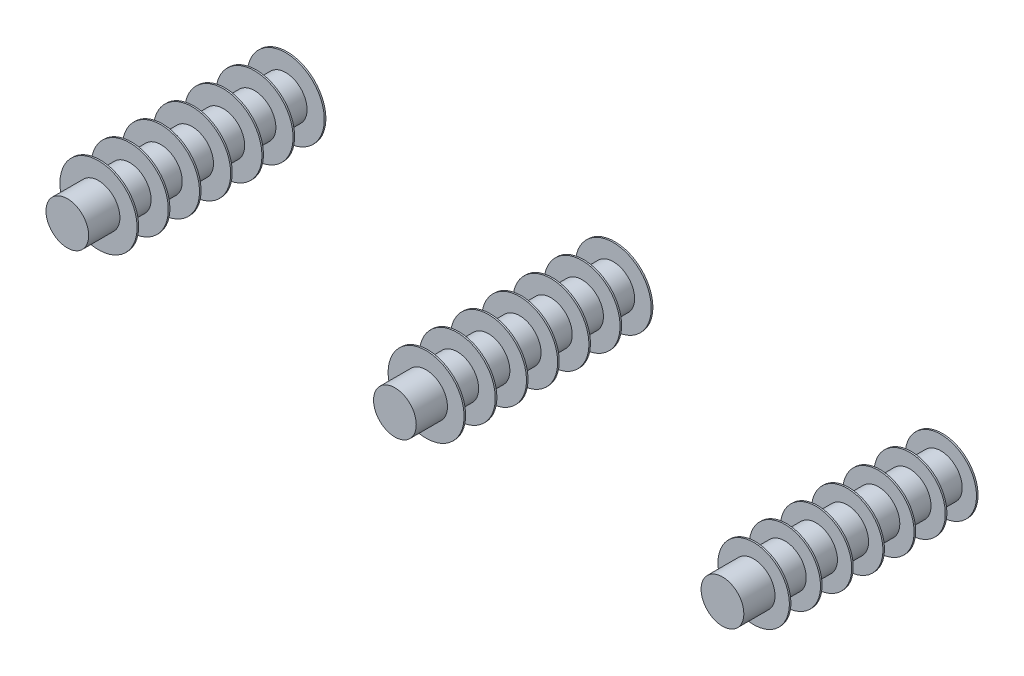
from build123d import *

# Parameters (mm, degrees)
BARRER5_PROFILE_R       = 13.7
BARRER6_PROFILE_R       = 13.7
CROQUIS41_R             = 13.7
CROQUIS62_R             = 22.870183784
CROQUIS62_R_2           = 24.36570856
CROQUIS62_R_3           = 24.738020287
SALIENTE_EXTRUIR1_DEPTH = 1
MATRIZL1_COUNT          = 7
MATRIZL1_PITCH          = 20
CROQUIS73_W             = 474.503225304
CROQUIS73_H             = 271.900955151
CORTAR_EXTRUIR2_DEPTH   = 450


with BuildPart() as part:
    # Barrer5: sweep along a curve in space
    with BuildLine() as barrer5_path:
        Line((0, 0, 0), (0, 0, 170))
        ThreePointArc((0, 0, 170), (8.786796564, 0, 191.213203436), (30, 0, 200))
        Line((30, 0, 200), (145.00018, 0, 200))
        ThreePointArc((145.00018, 0, 200), (166.213383436, 0, 208.786796564), (175.00018, 0, 230))
        Line((175.00018, 0, 230), (175.00018, 0, 500))
        ThreePointArc((175.00018, 0, 500), (175.00018, -5.857864376, 514.142135624), (175.00018, -20, 520))
        Line((175.00018, -20, 520), (175.00018, -156.800061359, 520))
    # Barrer5 profile (on start of the path) → Barrer5 (sweep)
    with BuildSketch(Plane.XY):
        Circle(BARRER5_PROFILE_R)
    sweep(path=barrer5_path.line)


with BuildPart() as body_2:
    # Barrer6: sweep along a curve in space
    with BuildLine() as barrer6_path:
        Line((210, 0, 0), (210, 0, 499.997033))
        ThreePointArc((210, 0, 499.997033), (210, -5.857864376, 514.139168624), (210, -20, 519.997033))
        Line((210, -20, 519.997033), (210, -153.425324093, 519.997033))
    # Barrer6 profile (on start of the path) → Barrer6 (sweep)
    with BuildSketch(Plane(origin=(210, 0, 0), x_dir=(1, 0, 0), z_dir=(0, 0, 1))):
        Circle(BARRER6_PROFILE_R)
    sweep(path=barrer6_path.line)


with BuildPart() as body_3:
    # Barrer7: sweep along a curve in space
    with BuildLine() as barrer7_path:
        Line((420, 0, 0), (420, 0, 180))
        ThreePointArc((420, 0, 180), (414.142135624, 0, 194.142135624), (400, 0, 200))
        Line((400, 0, 200), (264.998005, 0, 200))
        ThreePointArc((264.998005, 0, 200), (250.855869376, 0, 205.857864376), (244.998005, 0, 220))
        Line((244.998005, 0, 220), (244.998005, 0, 500))
        ThreePointArc((244.998005, 0, 500), (244.998005, -5.857864376, 514.142135624), (244.998005, -20, 520))
        Line((244.998005, -20, 520), (244.998005, -158.814937218, 520))
    # Croquis41 → Barrer7 (sweep)
    with BuildSketch(Plane(origin=(0, 0, 0), x_dir=(-1, 0, 0), z_dir=(0, 0, -1))):
        with Locations((-420, 0)):
            Circle(CROQUIS41_R)
    sweep(path=barrer7_path.line)

    # Croquis62 → Saliente-Extruir1 (add)
    with BuildSketch(Plane(origin=(0, 0, 0), x_dir=(-1, 0, 0), z_dir=(0, 0, -1))):
        with Locations((-420, 0)):
            Circle(CROQUIS62_R)
        with Locations((-210, 0)):
            Circle(CROQUIS62_R_2)
        Circle(CROQUIS62_R_3)
    saliente_extruir1 = extrude(amount=SALIENTE_EXTRUIR1_DEPTH)


with BuildPart() as saliente_extruir1_piece_1:
    # of the separate pieces the step leaves, piece 1, a body of its own (saliente_extruir1_pieces)
    add(body_3.part.solids().sort_by_distance((397.129816216, 0, 0))[0])


with BuildPart() as saliente_extruir1_piece_2:
    # of the separate pieces the step leaves, piece 2, a body of its own (saliente_extruir1_pieces)
    add(body_3.part.solids().sort_by_distance((-24.738020287, 0, 0))[0])


with BuildPart() as saliente_extruir1_piece_3:
    # of the separate pieces the step leaves, piece 3, a body of its own (saliente_extruir1_pieces)
    add(body_3.part.solids().sort_by_distance((185.63429144, 0, 0))[0])


with BuildPart() as part_1:
    add(part.part)

    add(body_2.part)  # MatrizL1 merges body 2

    add(saliente_extruir1_piece_1.part)  # MatrizL1 merges Saliente-Extruir1 piece 1
    # MatrizL1: Saliente-Extruir1 ×7
    with Locations(*[(0, 0, i * MATRIZL1_PITCH) for i in range(1, MATRIZL1_COUNT)]):
        add(saliente_extruir1)

    # Croquis73 → Cortar-Extruir2 (cut)
    with BuildSketch(Plane.XY.offset(590)):
        with Locations((218.376698867, -40.511270357)):
            Rectangle(CROQUIS73_W, CROQUIS73_H)
    extrude(amount=-CORTAR_EXTRUIR2_DEPTH, mode=Mode.SUBTRACT)


solid = Compound([saliente_extruir1_piece_2.part, saliente_extruir1_piece_3.part, part_1.part])
